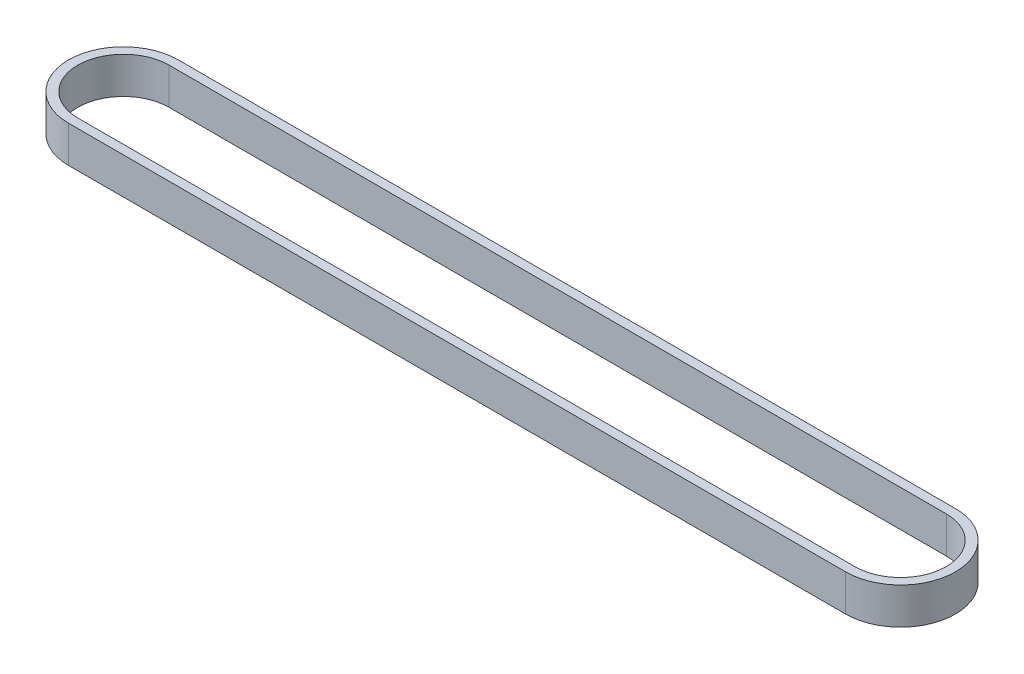
from build123d import *

# Parameters (mm, degrees)
BOSS_EXTRUDE1_DEPTH = 20


with BuildPart() as part:
    # Sketch1 → Boss-Extrude1 (new body)
    with BuildSketch(Plane(origin=(0, 0, 0), x_dir=(1, 0, 0), z_dir=(0, 1, 0))):
        with BuildLine():
            Line((-399.023443955, 41.02096112), (25.976556045, 41.02096112))
            ThreePointArc((25.976556045, 41.02096112), (55.976556045, 11.02096112), (25.976556045, -18.97903888))
            Line((25.976556045, -18.97903888), (-399.023443955, -18.97903888))
            ThreePointArc((-399.023443955, -18.97903888), (-429.023443955, 11.02096112), (-399.023443955, 41.02096112))
        make_face()
        with BuildLine():
            Line((-399.023443955, 36.02096112), (25.976556045, 36.02096112))
            ThreePointArc((25.976556045, 36.02096112), (50.976556045, 11.02096112), (25.976556045, -13.97903888))
            Line((25.976556045, -13.97903888), (-399.023443955, -13.97903888))
            ThreePointArc((-399.023443955, -13.97903888), (-424.023443955, 11.02096112), (-399.023443955, 36.02096112))
        make_face(mode=Mode.SUBTRACT)
    extrude(amount=BOSS_EXTRUDE1_DEPTH)


solid = part.part
